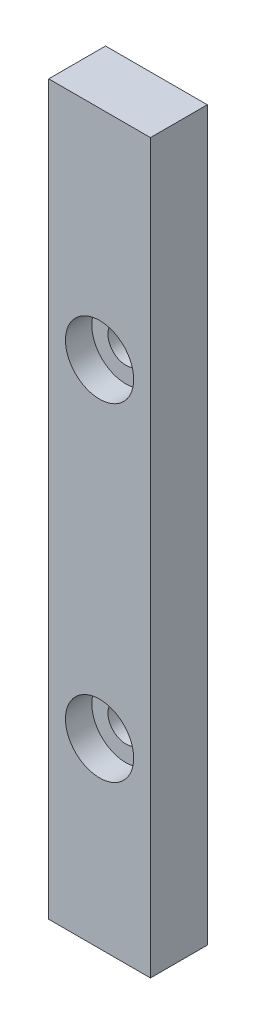
from build123d import *

# Parameters (mm, degrees)
SKETCH1_W                 = 8.5
SKETCH1_H                 = 60.8
BOSS_EXTRUDE1_DEPTH       = 4.75
F_3_0MM_DOWEL_HOLE1_D     = 3
F_3_0MM_DOWEL_HOLE1_DEPTH = 5
F_3_0MM_DOWEL_HOLE1_TIP   = 0.901290929
SKETCH6_R                 = 2.85
CUT_EXTRUDE1_DEPTH        = 2.2


with BuildPart() as part:
    # Sketch1 → Boss-Extrude1 (new body)
    with BuildSketch(Plane.XY):
        with Locations((4.25, -30.4)):
            Rectangle(SKETCH1_W, SKETCH1_H)
    extrude(amount=BOSS_EXTRUDE1_DEPTH)

    # Ø3.0mm Dowel Hole1
    with Locations(Plane.XY.offset(4.75)):
        with Locations((4.25, -18.2), (4.25, -45.6)):
            Hole(F_3_0MM_DOWEL_HOLE1_D / 2, depth=F_3_0MM_DOWEL_HOLE1_DEPTH)
            with Locations((0, 0, -(F_3_0MM_DOWEL_HOLE1_DEPTH + F_3_0MM_DOWEL_HOLE1_TIP / 2))):  # 118° drill point
                Cone(0, F_3_0MM_DOWEL_HOLE1_D / 2, F_3_0MM_DOWEL_HOLE1_TIP, mode=Mode.SUBTRACT)

    # Sketch6 → Cut-Extrude1 (cut)
    with BuildSketch(Plane.XY.offset(4.75)):
        with Locations((4.25, -18.2)):
            Circle(SKETCH6_R)
        with Locations((4.25, -45.6)):
            Circle(SKETCH6_R)
    extrude(amount=-CUT_EXTRUDE1_DEPTH, mode=Mode.SUBTRACT)


solid = part.part
